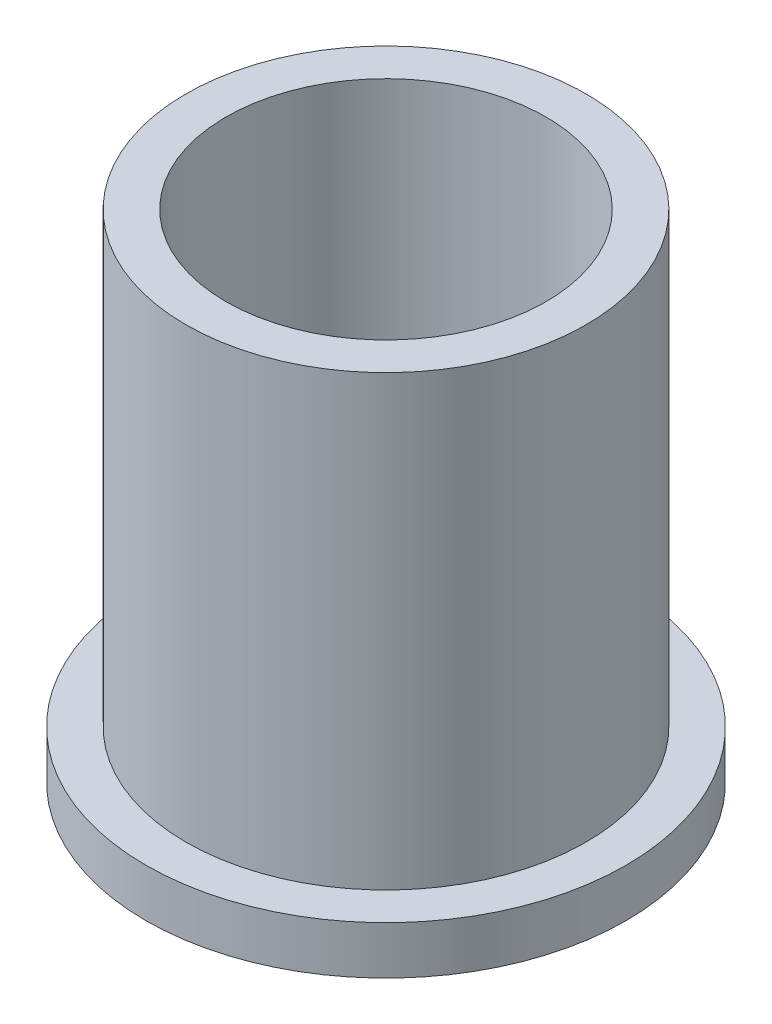
from build123d import *

# Parameters (mm, degrees)
SKETCH1_R               = 15
BOSS_EXTRUDE1_DEPTH     = 3
SKETCH1_3_R             = 12.5
BOSS_EXTRUDE2_DEPTH     = 31
CUT_EXTRUDE1_DEPTH      = 38.563279942
CUT_EXTRUDE1_DEPTH_BACK = 38.563279942
SKETCH1_4_R             = 10


with BuildPart() as part:
    # Sketch1 → Boss-Extrude1 (new body)
    with BuildSketch(Plane(origin=(0, 0, 0), x_dir=(1, 0, 0), z_dir=(0, 1, 0))):
        Circle(SKETCH1_R)
    extrude(amount=BOSS_EXTRUDE1_DEPTH)

    # Sketch1_3 → Boss-Extrude2 (add)
    with BuildSketch(Plane(origin=(0, 0, 0), x_dir=(1, 0, 0), z_dir=(0, 1, 0))):
        Circle(SKETCH1_3_R)
    extrude(amount=BOSS_EXTRUDE2_DEPTH)

    # Sketch1_4 → Cut-Extrude1 (cut, two sides: drawn at the far end of the back side and taken through both)
    with BuildSketch(Plane(origin=(0, 0, 0), x_dir=(1, 0, 0), z_dir=(0, 1, 0)).offset(-CUT_EXTRUDE1_DEPTH_BACK)):
        Circle(SKETCH1_4_R)
    extrude(amount=CUT_EXTRUDE1_DEPTH + CUT_EXTRUDE1_DEPTH_BACK, mode=Mode.SUBTRACT)


solid = part.part
